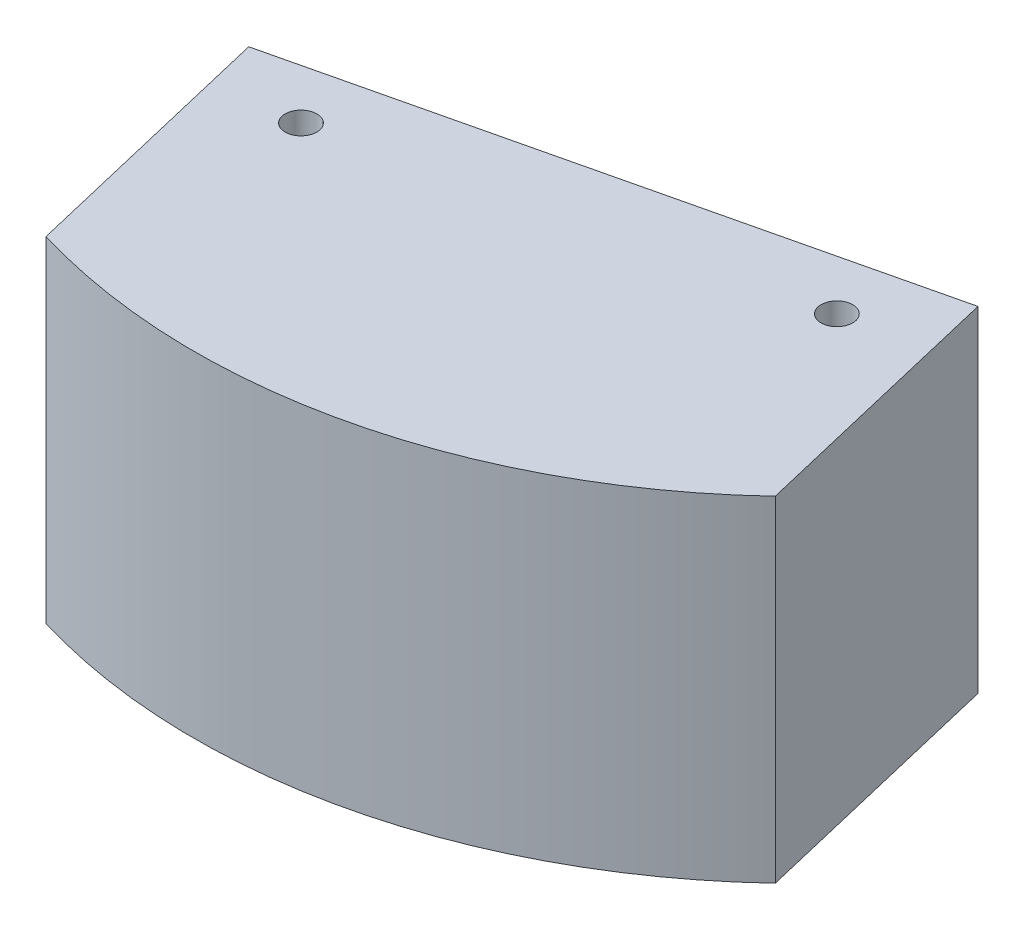
from build123d import *

# Parameters (mm, degrees)
BOSS_EXTRUDE1_DEPTH         = 50.8
F_12_0_189_DIAMETER_HOLE1_D = 4.8006


with BuildPart() as part:
    # Sketch1 → Boss-Extrude1 (new body)
    with BuildSketch(Plane(origin=(0, 0, 0), x_dir=(1, 0, 0), z_dir=(0, 1, 0))):
        with BuildLine():
            Line((63.017839503, -66.782093), (53.468205472, -26.506342671))
            Line((53.468205472, -26.506342671), (-35.875703335, -47.690346072))
            Line((-35.875703335, -47.690346072), (-26.326069304, -87.966096401))
            ThreePointArc((-26.326069304, -87.966096401), (21.184003401, -89.343908807), (63.017839503, -66.782093))
        make_face()
    extrude(amount=BOSS_EXTRUDE1_DEPTH)

    # #12 (0.189) Diameter Hole1 (through all)
    with Locations(Plane(origin=(0, 50.8, 0), x_dir=(1, 0, 0), z_dir=(0, 1, 0))):
        with Locations((-21.91216983, -53.736183096), (43.742627992, -38.169017556)):
            Hole(F_12_0_189_DIAMETER_HOLE1_D / 2)


solid = part.part
